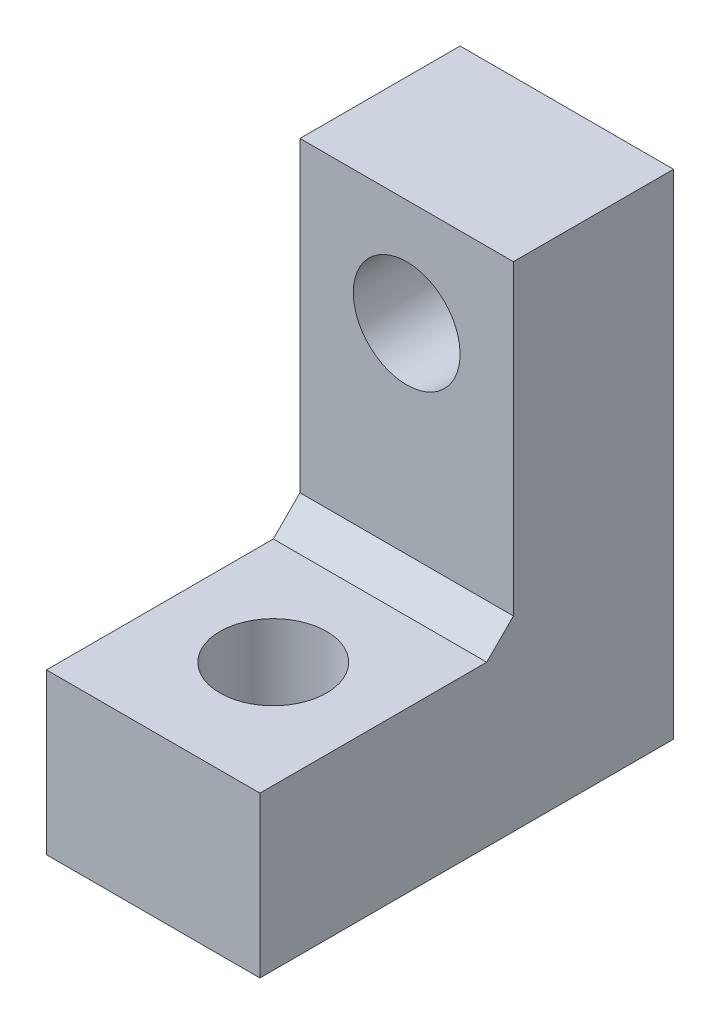
from build123d import *

# Parameters (mm, degrees)
SKETCH1_W           = 6
SKETCH1_H           = 12.5
SKETCH1_W_2         = 15.5
SKETCH1_H_2         = 6
BOSS_EXTRUDE1_DEPTH = 8
CHAMFER1_SIZE       = 1
SKETCH2_R           = 2
CUT_EXTRUDE1_DEPTH  = 6
SKETCH3_R           = 2
CUT_EXTRUDE2_DEPTH  = 7


with BuildPart() as part:
    # Sketch1 → Boss-Extrude1 (new body)
    with BuildSketch(Plane(origin=(0, 0, 0), x_dir=(0, 0, -1), z_dir=(1, 0, 0))):
        with Locations((12.5, 12.25)):
            Rectangle(SKETCH1_W, SKETCH1_H)
        with Locations((7.75, 3)):
            Rectangle(SKETCH1_W_2, SKETCH1_H_2)
    extrude(amount=BOSS_EXTRUDE1_DEPTH)

    # Chamfer1
    chamfer1_edges = [part.edges().sort_by_distance(p)[0] for p in [
        (4, 6, -9.5),
    ]]
    chamfer(chamfer1_edges, length=CHAMFER1_SIZE)

    # Sketch2 → Cut-Extrude1 (cut)
    with BuildSketch(Plane(origin=(0, 0, -15.5), x_dir=(-1, 0, 0), z_dir=(0, 0, -1))):
        with Locations((-4, 14.5)):
            Circle(SKETCH2_R)
        with Locations((-4, 4.5)):
            Circle(SKETCH2_R)
    extrude(amount=-CUT_EXTRUDE1_DEPTH, mode=Mode.SUBTRACT)

    # Sketch3 → Cut-Extrude2 (cut, through all)
    with BuildSketch(Plane(origin=(0, 6, 0), x_dir=(1, 0, 0), z_dir=(0, 1, 0))):
        with Locations((4, 4.5)):
            Circle(SKETCH3_R)
    extrude(amount=-CUT_EXTRUDE2_DEPTH, mode=Mode.SUBTRACT)


solid = part.part
